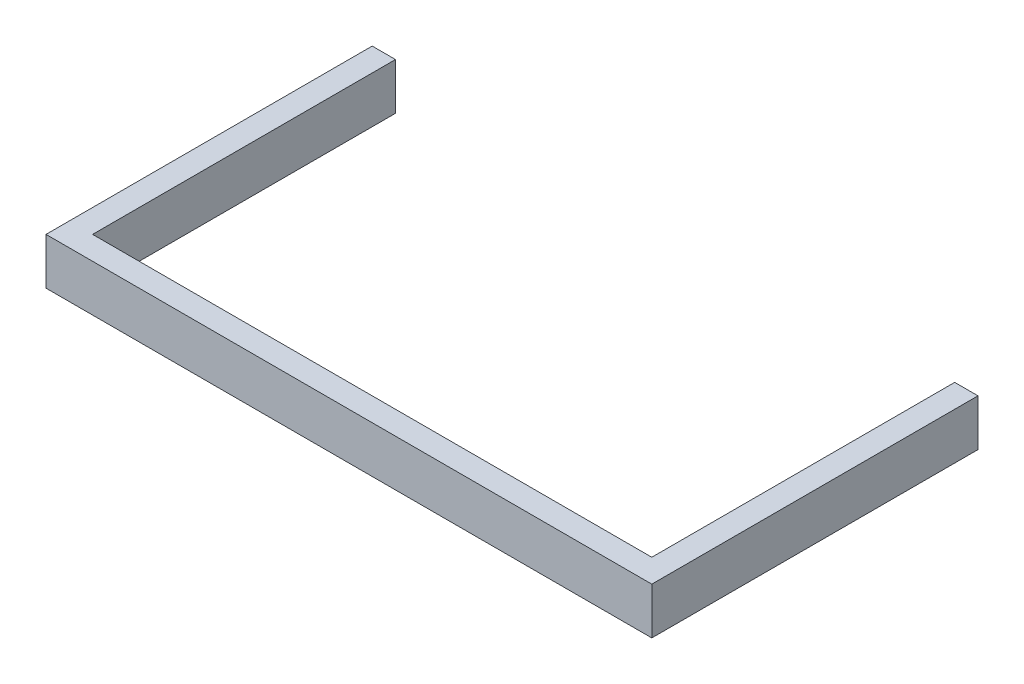
from build123d import *

# Parameters (mm, degrees)
BOSS_EXTRUDE1_DEPTH = 50.8


with BuildPart() as part:
    # Sketch1 → Boss-Extrude1 (new body)
    with BuildSketch(Plane(origin=(0, 0, 0), x_dir=(1, 0, 0), z_dir=(0, 1, 0))):
        Polygon((0, 25.4), (0, 0), (25.4, 0), (635, 0), (660.4, 0), (660.4, 25.4), (660.4, 355.6), (635, 355.6), (635, 339.647639714), (635, 25.4), (494.394032606, 25.4), (463.482544236, 25.4), (196.917455764, 25.4), (166.005967394, 25.4), (25.4, 25.4), (25.4, 339.647639714), (25.4, 355.6), (0, 355.6), align=None)
    extrude(amount=BOSS_EXTRUDE1_DEPTH)


solid = part.part
